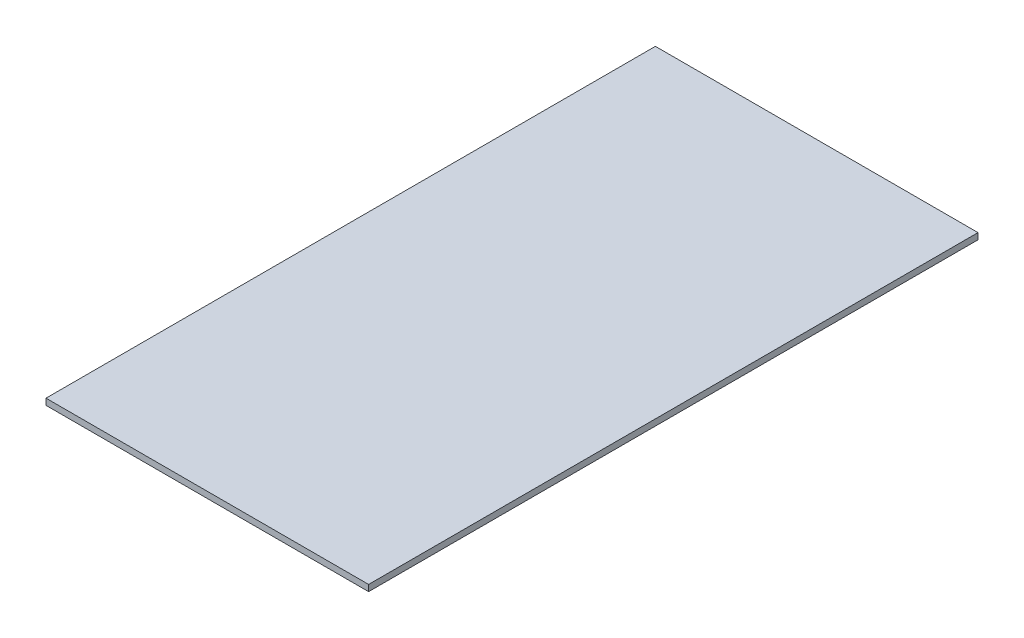
from build123d import *

# Parameters (mm, degrees)
SKETCH1_W           = 90
SKETCH1_H           = 170
BOSS_EXTRUDE1_DEPTH = 1.75


with BuildPart() as part:
    # Sketch1 → Boss-Extrude1 (new body)
    with BuildSketch(Plane(origin=(0, 0, 0), x_dir=(1, 0, 0), z_dir=(0, 1, 0))):
        with Locations((9.467759563, 24.62295082)):
            Rectangle(SKETCH1_W, SKETCH1_H)
    extrude(amount=BOSS_EXTRUDE1_DEPTH)


solid = part.part
